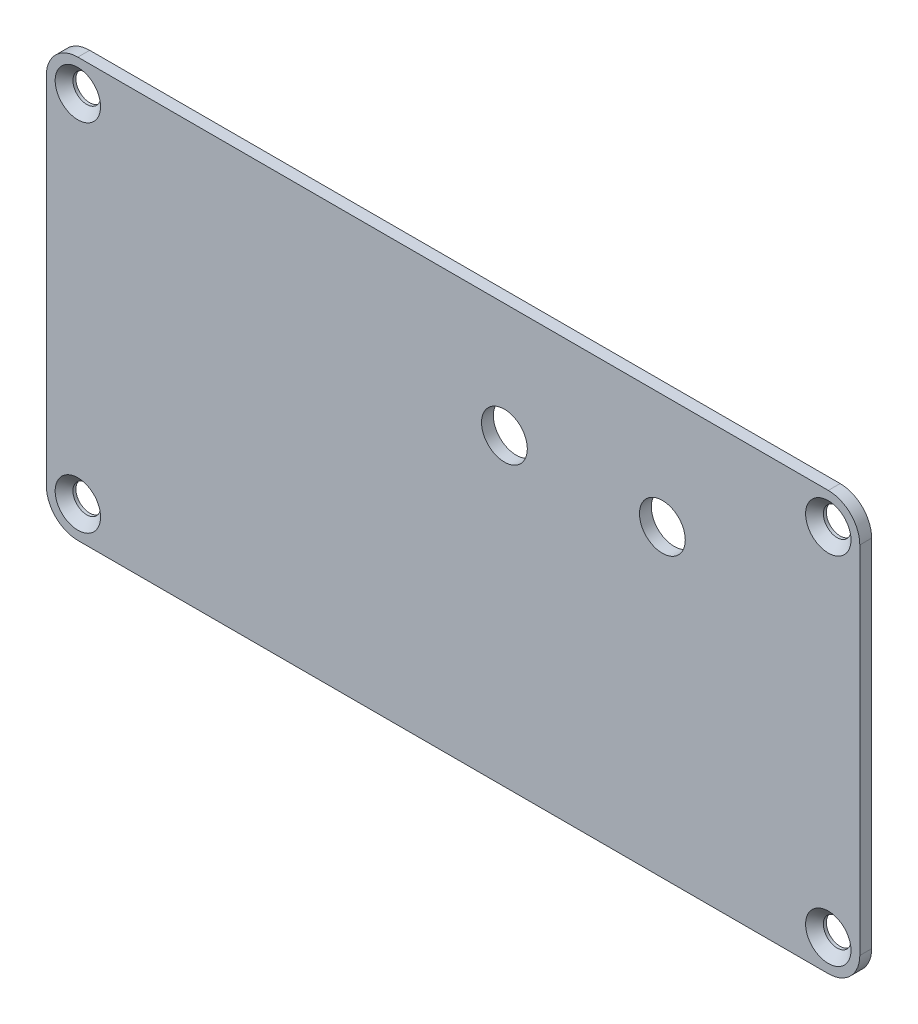
from build123d import *

# Parameters (mm, degrees)
ESQUISSE1_W                                 = 103
ESQUISSE1_H                                 = 53
BOSS_EXTRU_1_DEPTH                          = 1.5
FRAISAGE_POUR_VIS_T_TE_FRAIS_E_M31_AT_COUNT = 2
FRAISAGE_POUR_VIS_T_TE_FRAIS_E_M31_AT_PITCH = 95.02
FRAISAGE_POUR_VIS_T_TE_FRAIS_E_M31_2_COUNT  = 2
FRAISAGE_POUR_VIS_T_TE_FRAIS_E_M31_2_PITCH  = 105.137055314
FRAISAGE_POUR_VIS_T_TE_FRAIS_E_M31_3_COUNT  = 2
FRAISAGE_POUR_VIS_T_TE_FRAIS_E_M31_3_PITCH  = 45
CONG_1_R                                    = 3.99
ESQUISSE4_R                                 = 2.9
ENL_V_MAT_EXTRU_1_DEPTH                     = 2.5


with BuildPart() as part:
    # Esquisse1 → Boss.-Extru.1 (new body)
    with BuildSketch(Plane(origin=(0, 0, -0.75), x_dir=(-1, 0, 0), z_dir=(0, 0, -1))):
        Rectangle(ESQUISSE1_W, ESQUISSE1_H)
    extrude(amount=-BOSS_EXTRU_1_DEPTH)

    # Esquisse2 → Fraisage pour vis à tête fraisée M31 (revolve, cut)
    with BuildSketch(Plane(origin=(-47.51, 22.5, 0.75), x_dir=(0, -1, 0), z_dir=(1, 0, 0))):
        Polygon((0, 0), (0, 1.5), (1.75, 1.5), (1.75, 1.125), (2.875, 0), align=None)
    fraisage_pour_vis_t_te_frais_e_m31 = revolve(axis=Axis((-47.51, 22.5, 7.1), (0, 0, -1)), mode=Mode.SUBTRACT)

    # Fraisage pour vis à tête fraisée M31 at: Fraisage pour vis à tête fraisée M31 ×2
    with Locations(*[(i * FRAISAGE_POUR_VIS_T_TE_FRAIS_E_M31_AT_PITCH, 0, 0) for i in range(1, FRAISAGE_POUR_VIS_T_TE_FRAIS_E_M31_AT_COUNT)]):
        add(fraisage_pour_vis_t_te_frais_e_m31, mode=Mode.SUBTRACT)

    # Fraisage pour vis _ t_te frais_e M31 2: Fraisage pour vis à tête fraisée M31 ×2
    with Locations(*[Vector(0.903772697, -0.428012748, 0) * (i * FRAISAGE_POUR_VIS_T_TE_FRAIS_E_M31_2_PITCH) for i in range(1, FRAISAGE_POUR_VIS_T_TE_FRAIS_E_M31_2_COUNT)]):
        add(fraisage_pour_vis_t_te_frais_e_m31, mode=Mode.SUBTRACT)

    # Fraisage pour vis _ t_te frais_e M31 3: Fraisage pour vis à tête fraisée M31 ×2
    with Locations(*[(0, -i * FRAISAGE_POUR_VIS_T_TE_FRAIS_E_M31_3_PITCH, 0) for i in range(1, FRAISAGE_POUR_VIS_T_TE_FRAIS_E_M31_3_COUNT)]):
        add(fraisage_pour_vis_t_te_frais_e_m31, mode=Mode.SUBTRACT)

    # Congé1
    cong_1_edges = [part.edges().sort_by_distance(p)[0] for p in [
        (51.5, 26.5, 0),
        (-51.5, 26.5, 0),
        (-51.5, -26.5, 0),
        (51.5, -26.5, 0),
    ]]
    fillet(cong_1_edges, radius=CONG_1_R)

    # Esquisse4 → Enlèv. mat.-Extru.1 (cut, through all)
    with BuildSketch(Plane.XY.offset(0.75)):
        with Locations((26.5, 12)):
            Circle(ESQUISSE4_R)
        with Locations((6.5, 12)):
            Circle(ESQUISSE4_R)
    extrude(amount=-ENL_V_MAT_EXTRU_1_DEPTH, mode=Mode.SUBTRACT)


solid = part.part
